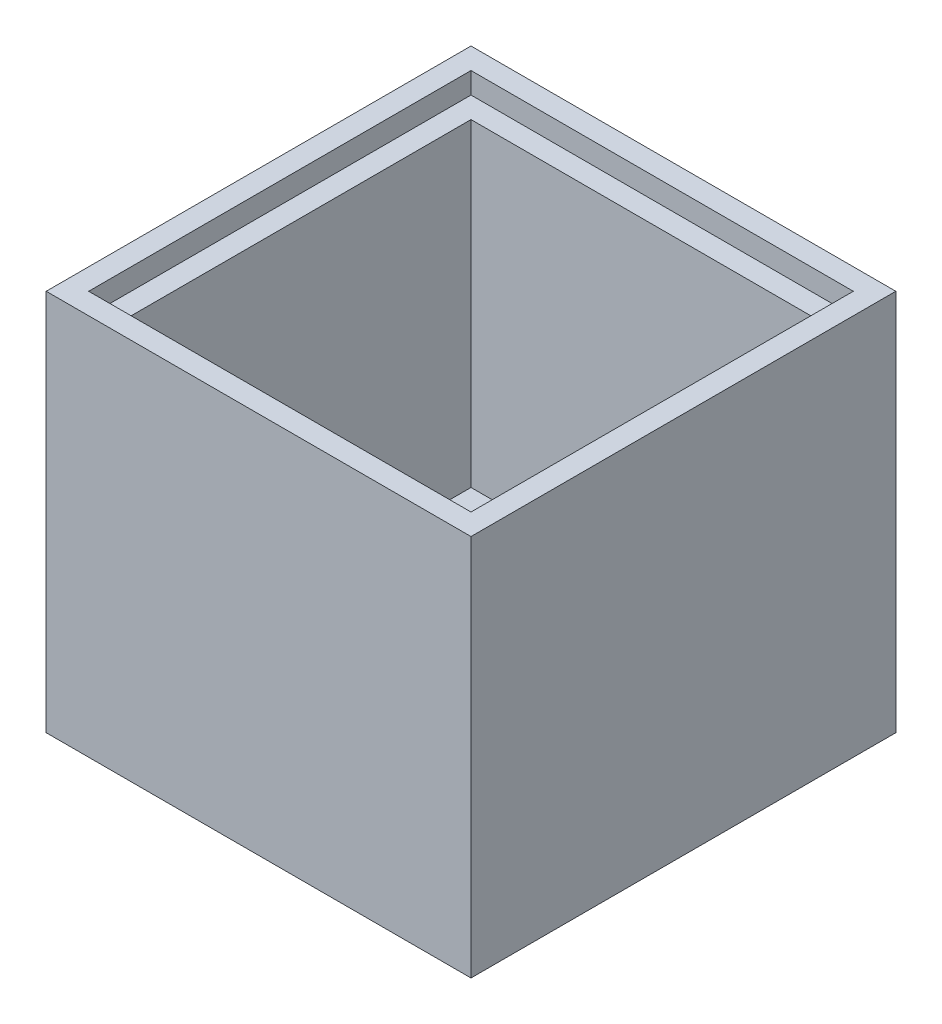
from build123d import *

# Parameters (mm, degrees)
CROQUIS1_W              = 50
CROQUIS1_H              = 50
SALIENTE_EXTRUIR1_DEPTH = 45
CROQUIS2_W              = 40
CROQUIS2_H              = 40
CORTAR_EXTRUIR1_DEPTH   = 40
CROQUIS3_W              = 45
CROQUIS3_H              = 45
CORTAR_EXTRUIR2_DEPTH   = 2.5


with BuildPart() as part:
    # Croquis1 → Saliente-Extruir1 (new body)
    with BuildSketch(Plane(origin=(0, 0, 0), x_dir=(1, 0, 0), z_dir=(0, 1, 0))):
        Rectangle(CROQUIS1_W, CROQUIS1_H)
    extrude(amount=SALIENTE_EXTRUIR1_DEPTH)

    # Croquis2 → Cortar-Extruir1 (cut)
    with BuildSketch(Plane(origin=(0, 45, 0), x_dir=(1, 0, 0), z_dir=(0, 1, 0))):
        Rectangle(CROQUIS2_W, CROQUIS2_H)
    extrude(amount=-CORTAR_EXTRUIR1_DEPTH, mode=Mode.SUBTRACT)

    # Croquis3 → Cortar-Extruir2 (cut)
    with BuildSketch(Plane(origin=(0, 45, 0), x_dir=(1, 0, 0), z_dir=(0, 1, 0))):
        Rectangle(CROQUIS3_W, CROQUIS3_H)
    extrude(amount=-CORTAR_EXTRUIR2_DEPTH, mode=Mode.SUBTRACT)


solid = part.part
